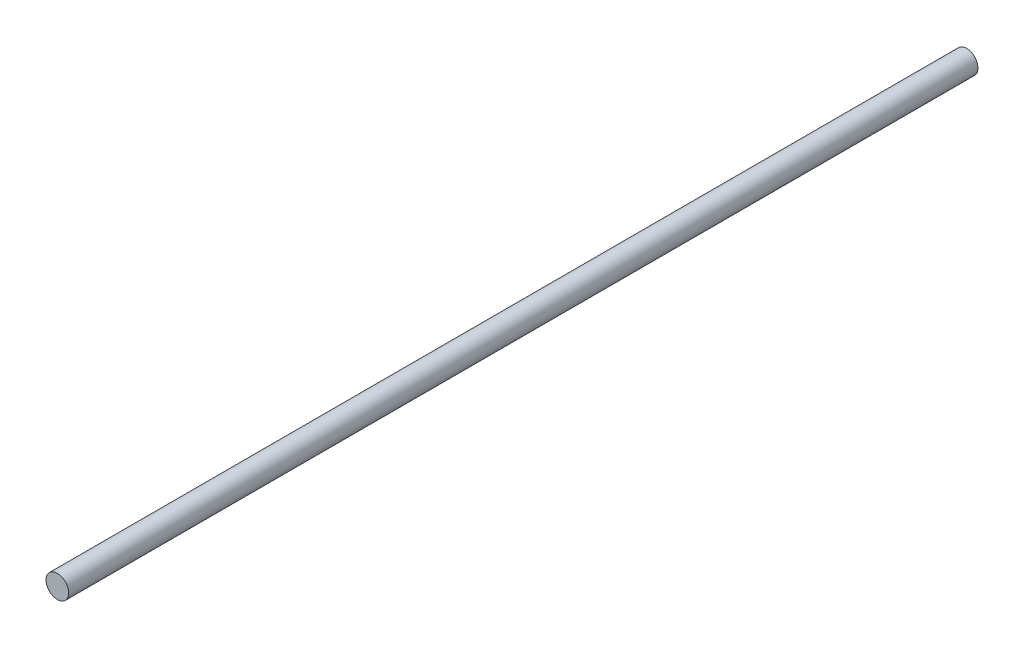
from build123d import *

# Parameters (mm, degrees)
ESQUISSE1_R        = 1
BOSS_EXTRU_1_DEPTH = 80


with BuildPart() as part:
    # Esquisse1 → Boss.-Extru.1 (new body)
    with BuildSketch(Plane.XY):
        Circle(ESQUISSE1_R)
    extrude(amount=BOSS_EXTRU_1_DEPTH)


solid = part.part
